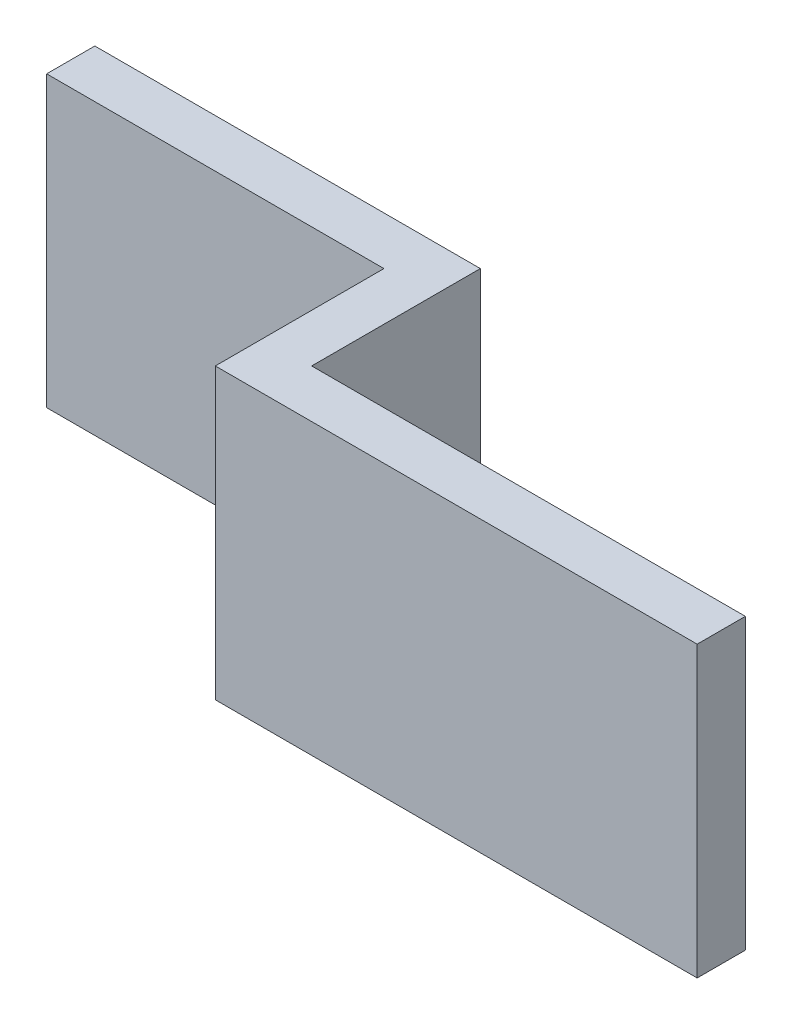
from build123d import *

# Parameters (mm, degrees)
SKETCH1_W           = 7
SKETCH1_H           = 1
BOSS_EXTRUDE1_DEPTH = 3


with BuildPart() as part:
    # Sketch1 → Boss-Extrude1 (new body, symmetric)
    with BuildSketch(Plane(origin=(0, 0, 0), x_dir=(1, 0, 0), z_dir=(0, 1, 0))):
        with Locations((-3.5, 0)):
            Rectangle(SKETCH1_W, SKETCH1_H)
        Polygon((1, 0.5), (0, 0.5), (0, -0.5), (0, -4), (10, -4), (10, -3), (1, -3), align=None)
    extrude(amount=BOSS_EXTRUDE1_DEPTH, both=True)


solid = part.part
